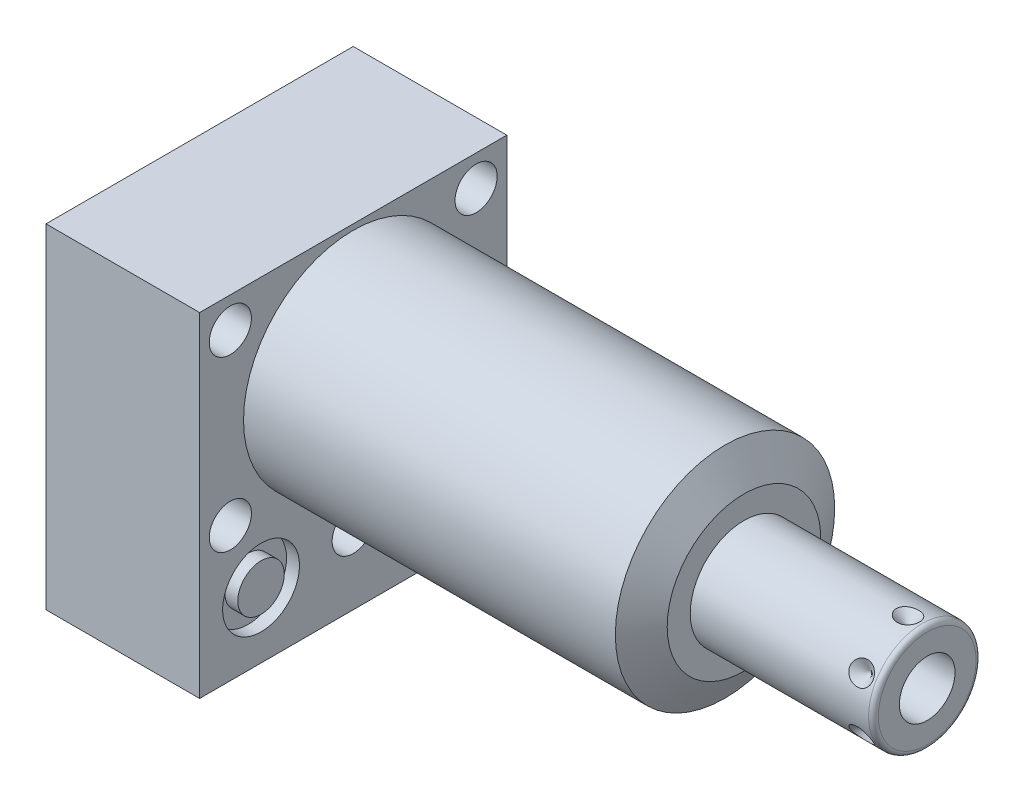
from build123d import *

# Parameters (mm, degrees)
SKETCH1_W           = 63.5
SKETCH1_H           = 69.088
EXTRUDE1_DEPTH      = 80.772
EXTRUDE1_DEPTH_BACK = 31.75
CUT_EXTRUDE1_REACH  = 82.772
SKETCH2_W           = 63.5
SKETCH2_H           = 69.088
SKETCH2_R           = 22.6695
SKETCH18_R          = 7.9375
CUT_EXTRUDE2_DEPTH  = 2.667
SKETCH19_R          = 7.9375
CUT_EXTRUDE3_DEPTH  = 2.667
SKETCH20_R          = 9.525
CUT_EXTRUDE4_DEPTH  = 0.254
SKETCH12_R          = 6.4389
EXTRUDE2_DEPTH      = 1.651
EXTRUDE3_START      = -31.75
SKETCH13_R          = 4.8006
EXTRUDE3_DEPTH      = 31.75
SKETCH14_R          = 1.7653
SKETCH15_R          = 1.7653
CIRPATTERN1_COUNT   = 6
SKETCH21_W          = 4.3561
SKETCH21_H          = 31.75
HOLE1_AT_2_COUNT    = 2
HOLE1_AT_2_PITCH    = 54.58107178
HOLE1_AT_3_COUNT    = 2
HOLE1_AT_3_PITCH    = 34.9504
HOLE1_AT_4_COUNT    = 2
HOLE1_AT_4_PITCH    = 50.8
HOLE1_AT_5_COUNT    = 2
HOLE1_AT_5_PITCH    = 61.661742273


with BuildPart() as part:
    # Sketch1 → Extrude1 (new body, two sides)
    with BuildSketch(Plane(origin=(0, 0, 0), x_dir=(0, 0, -1), z_dir=(1, 0, 0))) as extrude1_sk:
        with Locations((0, -10.7188)):
            Rectangle(SKETCH1_W, SKETCH1_H)
    extrude(amount=EXTRUDE1_DEPTH)
    extrude(extrude1_sk.sketch, amount=-EXTRUDE1_DEPTH_BACK)

    # Sketch2 → Cut-Extrude1 (cut, up to next)
    with BuildSketch(Plane(origin=(0, 0, 0), x_dir=(0, 0, -1), z_dir=(1, 0, 0)), mode=Mode.PRIVATE) as cut_extrude1_sk1:
        with Locations((0, -10.7188)):
            Rectangle(SKETCH2_W, SKETCH2_H)
        Circle(SKETCH2_R, mode=Mode.SUBTRACT)
    cut_extrude1_tool1 = extrude(cut_extrude1_sk1.sketch, amount=CUT_EXTRUDE1_REACH, mode=Mode.PRIVATE) & part.part
    add(cut_extrude1_tool1.solids().sort_by_distance((0, 22.886829, 0))[0], mode=Mode.SUBTRACT)

    # Sketch3 → Cut-Revolve1 (revolve, cut)
    with BuildSketch(Plane.XY, mode=Mode.PRIVATE) as cut_revolve1_sk:
        Polygon((76.849193596, 22.6695), (80.772, 15.875), (80.772, 22.6695), align=None)
    revolve(cut_revolve1_sk.sketch.rotate(Axis((76.037136009, 0, 0), (1, 0, 0)), 90), axis=Axis((76.037136009, 0, 0), (1, 0, 0)), mode=Mode.SUBTRACT)  # turned: the seam where the file's is

    # S2D0002 → Cut-Revolve2 (revolve, cut)
    with BuildSketch(Plane(origin=(-29.083, -31.75, 19.05), x_dir=(0, 1, 0), z_dir=(0, 0, 1)), mode=Mode.PRIVATE) as cut_revolve2_sk:
        Polygon((0, 0), (4.5466, 0), (4.106586662, -2.0701), (3.4544, -2.722286662), (3.4544, -13.97), (0, -13.97), align=None)
    revolve(cut_revolve2_sk.sketch.rotate(Axis((-14.4145, -31.75, 19.05), (-1, 0, 0)), 90), axis=Axis((-14.4145, -31.75, 19.05), (-1, 0, 0)), mode=Mode.SUBTRACT)  # turned: the seam where the file's is

    # Sketch5 → Cut-Revolve3 (revolve, cut)
    with BuildSketch(Plane(origin=(-29.083, -31.75, -19.05), x_dir=(0, 1, 0), z_dir=(0, 0, 1)), mode=Mode.PRIVATE) as cut_revolve3_sk:
        Polygon((0, 0), (4.5466, 0), (4.106586662, -2.0701), (3.4544, -2.722286662), (3.4544, -13.97), (0, -13.97), align=None)
    revolve(cut_revolve3_sk.sketch.rotate(Axis((-14.4145, -31.75, -19.05), (-1, 0, 0)), 90), axis=Axis((-14.4145, -31.75, -19.05), (-1, 0, 0)), mode=Mode.SUBTRACT)  # turned: the seam where the file's is

    # Sketch6 → Cut-Revolve4 (revolve, cut)
    with BuildSketch(Plane(origin=(-2.667, -31.75, 19.05), x_dir=(0, -1, 0), z_dir=(0, 0, 1)), mode=Mode.PRIVATE) as cut_revolve4_sk:
        Polygon((0, 0), (4.5466, 0), (4.106586662, -2.0701), (3.4544, -2.722286662), (3.4544, -12.192), (0, -12.192), align=None)
    revolve(cut_revolve4_sk.sketch.rotate(Axis((-15.4686, -31.75, 19.05), (1, 0, 0)), 90), axis=Axis((-15.4686, -31.75, 19.05), (1, 0, 0)), mode=Mode.SUBTRACT)  # turned: the seam where the file's is

    # Sketch7 → Cut-Revolve5 (revolve, cut)
    with BuildSketch(Plane(origin=(-2.667, -31.75, -19.05), x_dir=(0, -1, 0), z_dir=(0, 0, 1)), mode=Mode.PRIVATE) as cut_revolve5_sk:
        Polygon((0, 0), (4.5466, 0), (4.106586662, -2.0701), (3.4544, -2.722286662), (3.4544, -12.192), (0, -12.192), align=None)
    revolve(cut_revolve5_sk.sketch.rotate(Axis((-15.4686, -31.75, -19.05), (1, 0, 0)), 90), axis=Axis((-15.4686, -31.75, -19.05), (1, 0, 0)), mode=Mode.SUBTRACT)  # turned: the seam where the file's is

    # Sketch8 → Cut-Revolve6 (revolve, cut)
    with BuildSketch(Plane(origin=(-15.875, -51.6128, 19.05), x_dir=(-1, 0, 0), z_dir=(0, 0, 1)), mode=Mode.PRIVATE) as cut_revolve6_sk:
        Polygon((0, -6.604), (6.1849, -6.604), (5.642306865, -9.1567), (4.9784, -9.820606865), (4.9784, -25.654), (0, -25.654), align=None)
    revolve(cut_revolve6_sk.sketch.rotate(Axis((-15.875, -24.9428, 19.05), (0, -1, 0)), 270), axis=Axis((-15.875, -24.9428, 19.05), (0, -1, 0)), mode=Mode.SUBTRACT)  # turned: the seam where the file's is

    # Sketch9 → Cut-Revolve7 (revolve, cut)
    with BuildSketch(Plane(origin=(-15.875, -51.6128, -19.05), x_dir=(-1, 0, 0), z_dir=(0, 0, 1)), mode=Mode.PRIVATE) as cut_revolve7_sk:
        Polygon((0, -6.604), (6.1849, -6.604), (5.642306865, -9.1567), (4.9784, -9.820606865), (4.9784, -25.654), (0, -25.654), align=None)
    revolve(cut_revolve7_sk.sketch.rotate(Axis((-15.875, -24.9428, -19.05), (0, -1, 0)), 270), axis=Axis((-15.875, -24.9428, -19.05), (0, -1, 0)), mode=Mode.SUBTRACT)  # turned: the seam where the file's is

    # Sketch18 → Cut-Extrude2 (cut)
    with BuildSketch(Plane(origin=(0, 0, 0), x_dir=(0, 0, -1), z_dir=(1, 0, 0))):
        with Locations((-19.05, -31.75)):
            Circle(SKETCH18_R)
        with Locations((19.05, -31.75)):
            Circle(SKETCH18_R)
    extrude(amount=-CUT_EXTRUDE2_DEPTH, mode=Mode.SUBTRACT)

    # Sketch19 → Cut-Extrude3 (cut)
    with BuildSketch(Plane.ZY.offset(31.75)):
        with Locations(Location((-19.05, -31.75, 0), (0, 0, 180))):  # turned: the seam where the file's is
            Circle(SKETCH19_R)
        with Locations(Location((19.05, -31.75, 0), (0, 0, 180))):  # turned: the seam where the file's is
            Circle(SKETCH19_R)
    extrude(amount=-CUT_EXTRUDE3_DEPTH, mode=Mode.SUBTRACT)

    # Sketch20 → Cut-Extrude4 (cut)
    with BuildSketch(Plane.XZ.offset(45.2628)):
        with Locations(Location((-15.875, -19.05, 0), (0, 0, 270))):  # turned: the seam where the file's is
            Circle(SKETCH20_R)
        with Locations(Location((-15.875, 19.05, 0), (0, 0, 270))):  # turned: the seam where the file's is
            Circle(SKETCH20_R)
    extrude(amount=-CUT_EXTRUDE4_DEPTH, mode=Mode.SUBTRACT)

    # Sketch10 → Revolve1 (revolve)
    with BuildSketch(Plane.XY, mode=Mode.PRIVATE) as revolve1_sk:
        with BuildLine():
            Line((80.772, 0), (80.772, 11.1125))
            Line((80.772, 11.1125), (117.6274, 11.1125))
            ThreePointArc((117.6274, 11.1125), (118.34582049, 10.81492049), (118.6434, 10.0965))
            Line((118.6434, 10.0965), (118.6434, 0))
            Line((118.6434, 0), (80.772, 0))
        make_face()
    revolve(revolve1_sk.sketch.rotate(Axis((58.270820274, 0, 0), (1, 0, 0)), 90), axis=Axis((58.270820274, 0, 0), (1, 0, 0)))  # turned: the seam where the file's is

    # S2D0001 → Cut-Revolve8 (revolve, cut)
    with BuildSketch(Plane(origin=(118.6434, -5.7531, 0), x_dir=(0, -1, 0), z_dir=(0, 0, 1)), mode=Mode.PRIVATE) as cut_revolve8_sk:
        Polygon((0, 0), (0, -17.018), (-5.7531, -20.474811227), (-5.7531, 0), align=None)
    revolve(cut_revolve8_sk.sketch.rotate(Axis((84.296273767, 0, 0), (1, 0, 0)), 270), axis=Axis((84.296273767, 0, 0), (1, 0, 0)), mode=Mode.SUBTRACT)  # turned: the seam where the file's is

    # Sketch12 → Extrude2 (add)
    with BuildSketch(Plane.XZ.offset(45.0088)):
        with Locations(Location((-15.875, 19.05, 0), (0, 0, 270))):  # turned: the seam where the file's is
            Circle(SKETCH12_R)
    extrude(amount=EXTRUDE2_DEPTH)

    # Sketch13 → Extrude3 (add)
    with BuildSketch(Plane(origin=(0, 0, 0), x_dir=(0, 0, -1), z_dir=(1, 0, 0)).offset(EXTRUDE3_START)):
        with Locations((-19.05, -31.75)):
            Circle(SKETCH13_R)
    extrude(amount=EXTRUDE3_DEPTH)

    # Sketch16 → Cut-Revolve9 (revolve, cut)
    with BuildSketch(Plane(origin=(114.681, -11.1125, 0), x_dir=(-1, 0, 0), z_dir=(0, 0, 1)), mode=Mode.PRIVATE) as cut_revolve9_sk:
        Polygon((0, 0), (2.413, 0), (0, -2.413), align=None)
    cut_revolve9 = revolve(cut_revolve9_sk.sketch.rotate(Axis((114.681, -6.093194843, 0), (0, -1, 0)), 90), axis=Axis((114.681, -6.093194843, 0), (0, -1, 0)), mode=Mode.SUBTRACT)  # turned: the seam where the file's is

    # CirPattern1: Cut-Revolve9 ×6 about axis
    cirpattern1_axis = Axis((0, 0, 0), (-1, 0, 0))
    for i in range(1, CIRPATTERN1_COUNT):
        add(cut_revolve9.rotate(cirpattern1_axis, i * 360 / CIRPATTERN1_COUNT), mode=Mode.SUBTRACT)

    # Sketch21 → Hole1 (revolve, cut)
    with BuildSketch(Plane(origin=(0, 17.4752, 25.4), x_dir=(0, 0, -1), z_dir=(0, 1, 0))):
        with Locations((2.17805, 15.875)):
            Rectangle(SKETCH21_W, SKETCH21_H)
    hole1 = revolve(axis=Axis((-110, 17.4752, 25.4), (1, 0, 0)), mode=Mode.SUBTRACT)

    # Hole1 at 2: Hole1 ×2
    with Locations(*[Vector(0, -0.885120032, -0.465362793) * (i * HOLE1_AT_2_PITCH) for i in range(1, HOLE1_AT_2_COUNT)]):
        add(hole1, mode=Mode.SUBTRACT)

    # Hole1 at 3: Hole1 ×2
    with Locations(*[(0, -i * HOLE1_AT_3_PITCH, 0) for i in range(1, HOLE1_AT_3_COUNT)]):
        add(hole1, mode=Mode.SUBTRACT)

    # Hole1 at 4: Hole1 ×2
    with Locations(*[(0, 0, -i * HOLE1_AT_4_PITCH) for i in range(1, HOLE1_AT_4_COUNT)]):
        add(hole1, mode=Mode.SUBTRACT)

    # Hole1 at 5: Hole1 ×2
    with Locations(*[Vector(0, -0.566808506, -0.823849572) * (i * HOLE1_AT_5_PITCH) for i in range(1, HOLE1_AT_5_COUNT)]):
        add(hole1, mode=Mode.SUBTRACT)


with BuildPart() as body_2:
    # Sketch14 → Revolve2 (revolve)
    with BuildSketch(Plane(origin=(0, -31.75, -19.05), x_dir=(0, 0, -1), z_dir=(0, -1, 0)), mode=Mode.PRIVATE) as revolve2_sk:
        with Locations((6.1722, -0.9017)):
            Circle(SKETCH14_R)
    revolve(revolve2_sk.sketch.rotate(Axis((-2.84353, -31.75, -19.05), (1, 0, 0)), 180), axis=Axis((-2.84353, -31.75, -19.05), (1, 0, 0)))  # turned: the seam where the file's is


with BuildPart() as body_3:
    # Sketch15 → Revolve3 (revolve)
    with BuildSketch(Plane(origin=(0, -31.75, -19.05), x_dir=(0, 0, -1), z_dir=(0, -1, 0)), mode=Mode.PRIVATE) as revolve3_sk:
        with Locations((6.1722, -30.8483)):
            Circle(SKETCH15_R)
    revolve(revolve3_sk.sketch.rotate(Axis((-32.79013, -31.75, -19.05), (1, 0, 0)), 180), axis=Axis((-32.79013, -31.75, -19.05), (1, 0, 0)))  # turned: the seam where the file's is


solid = Compound([part.part, body_2.part, body_3.part])
